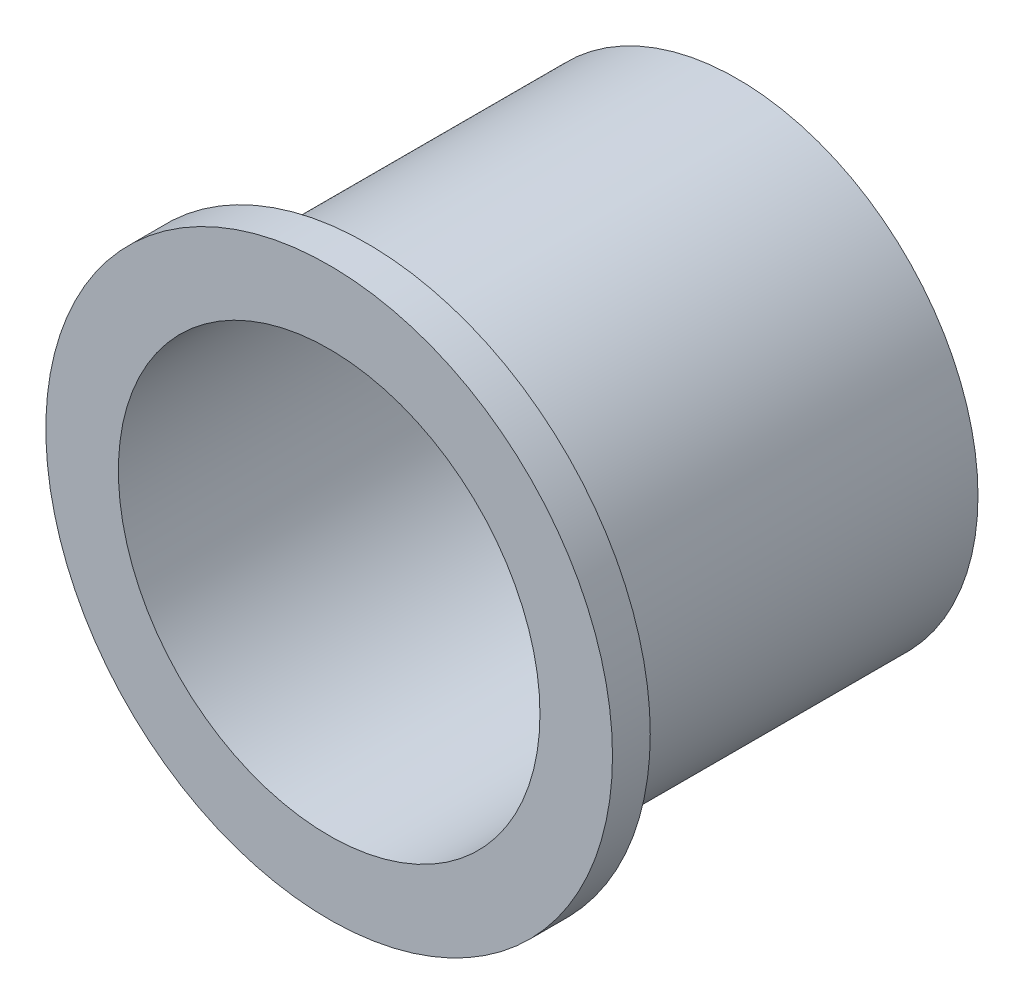
from build123d import *


with BuildPart() as part:
    # Revolve Sketch → Revolve Body (revolve)
    with BuildSketch(Plane(origin=(0, 0, 0), x_dir=(0, 0, -1), z_dir=(1, 0, 0))):
        Polygon((0, 190.5), (0, 141.732), (274.32, 141.732), (274.32, 161.925), (25.4, 161.925), (25.4, 190.5), align=None)
    revolve(axis=Axis((0, 0, 0), (0, 0, -1)))


solid = part.part
